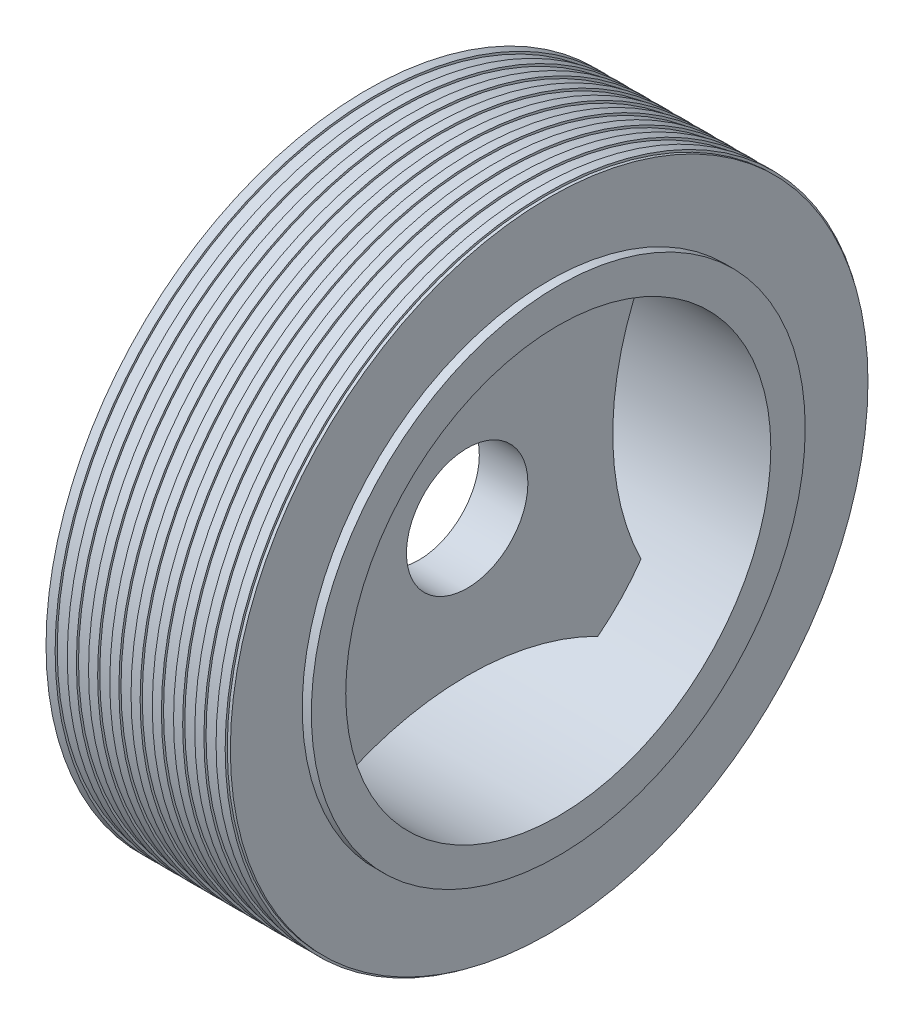
from build123d import *
from build123d.topology import SkipClean

# Parameters (mm, degrees)
SKETCH2_R                = 81.32791599
SKETCH2_R_2              = 20
BOSS_EXTRUDE1_DEPTH      = 3
BOSS_EXTRUDE1_DEPTH_BACK = 63
SKETCH3_R                = 70
CUT_EXTRUDE1_DEPTH       = 30
SKETCH4_R                = 70
CUT_EXTRUDE2_DEPTH       = 20
CUT_EXTRUDE3_DEPTH       = 20
CUT_EXTRUDE3_DEPTH_BACK  = 30
SKETCH6_R                = 2.5934664
BOSS_EXTRUDE2_DEPTH      = 2


with BuildPart() as part:
    # Sketch1 → Revolve1 (revolve)
    with BuildSketch(Plane.XY, mode=Mode.PRIVATE) as revolve1_sk:
        Polygon((25, 100), (25, 75), (30, 75), (30, 105), (29, 105), (29, 105.702764037), (26, 105.702764037), (26, 105), (22, 105), (22, 105.702764037), (19, 105.702764037), (19, 105), (15, 105), (15, 105.702764037), (12, 105.702764037), (12, 105), (8, 105), (8, 105.702764037), (5, 105.702764037), (5, 105), (1, 105), (1, 105.702764037), (-2, 105.702764037), (-2, 105), (-6, 105), (-6, 105.702764037), (-9, 105.702764037), (-9, 105), (-13, 105), (-13, 105.702764037), (-16, 105.702764037), (-16, 105), (-20, 105), (-20, 105.702764037), (-23, 105.702764037), (-23, 105), (-27, 105), (-27, 105.702764037), (-30, 105.702764037), (-30, 75), (-25, 75), (-25, 100), align=None)
    revolve(revolve1_sk.sketch.rotate(Axis((-60.37659433, 0, 0), (1, 0, 0)), 90), axis=Axis((-60.37659433, 0, 0), (1, 0, 0)))

    # Sketch2 → Boss-Extrude1 (add, two sides)
    with BuildSketch(Plane(origin=(30, 0, 0), x_dir=(0, 0, -1), z_dir=(1, 0, 0))) as boss_extrude1_sk:
        Circle(SKETCH2_R)
        Circle(SKETCH2_R_2, mode=Mode.SUBTRACT)
    extrude(amount=BOSS_EXTRUDE1_DEPTH)
    extrude(boss_extrude1_sk.sketch, amount=-BOSS_EXTRUDE1_DEPTH_BACK)

    # Sketch3 → Cut-Extrude1 (cut)
    with BuildSketch(Plane(origin=(33, 0, 0), x_dir=(0, 0, -1), z_dir=(1, 0, 0))):
        Circle(SKETCH3_R)
    extrude(amount=-CUT_EXTRUDE1_DEPTH, mode=Mode.SUBTRACT)

    # Sketch4 → Cut-Extrude2 (cut)
    with BuildSketch(Plane.ZY.offset(33)):
        with Locations(Location((0, 0, 0), (0, 0, 180))):
            Circle(SKETCH4_R)
    extrude(amount=-CUT_EXTRUDE2_DEPTH, mode=Mode.SUBTRACT)

    # Sketch5 → Cut-Extrude3 (cut, two sides)
    with SkipClean():  # the faces are left unmerged after this step: merging them gives an invalid solid
        with BuildSketch(Plane(origin=(3, 0, 0), x_dir=(0, 0, -1), z_dir=(1, 0, 0))) as cut_extrude3_sk:
            with BuildLine():
                ThreePointArc((-57.241605299, 40.291421206), (-47.954627948, 0), (-57.241605299, -40.291421206))
                ThreePointArc((-57.241605299, -40.291421206), (-70, 0), (-57.241605299, 40.291421206))
            make_face()
            with BuildLine():
                ThreePointArc((-43.034620977, -55.208888753), (0, -44.913138925), (43.034620977, -55.208888753))
                ThreePointArc((43.034620977, -55.208888753), (0, -70), (-43.034620977, -55.208888753))
            make_face()
            with BuildLine():
                ThreePointArc((57.241605299, 40.291421206), (47.954627948, 0), (57.241605299, -40.291421206))
                ThreePointArc((57.241605299, -40.291421206), (70, 0), (57.241605299, 40.291421206))
            make_face()
            with BuildLine():
                ThreePointArc((-43.034620977, 55.208888753), (0, 44.913138925), (43.034620977, 55.208888753))
                ThreePointArc((43.034620977, 55.208888753), (0, 70), (-43.034620977, 55.208888753))
            make_face()
        extrude(amount=CUT_EXTRUDE3_DEPTH, mode=Mode.SUBTRACT)
        extrude(cut_extrude3_sk.sketch, amount=-CUT_EXTRUDE3_DEPTH_BACK, mode=Mode.SUBTRACT)

    # Sketch6 → Boss-Extrude2 (add)
    with BuildSketch(Plane.ZY.offset(13)):
        with Locations((-33.454711328, 29.112032454)):
            Circle(SKETCH6_R)
    extrude(amount=BOSS_EXTRUDE2_DEPTH)


solid = part.part
